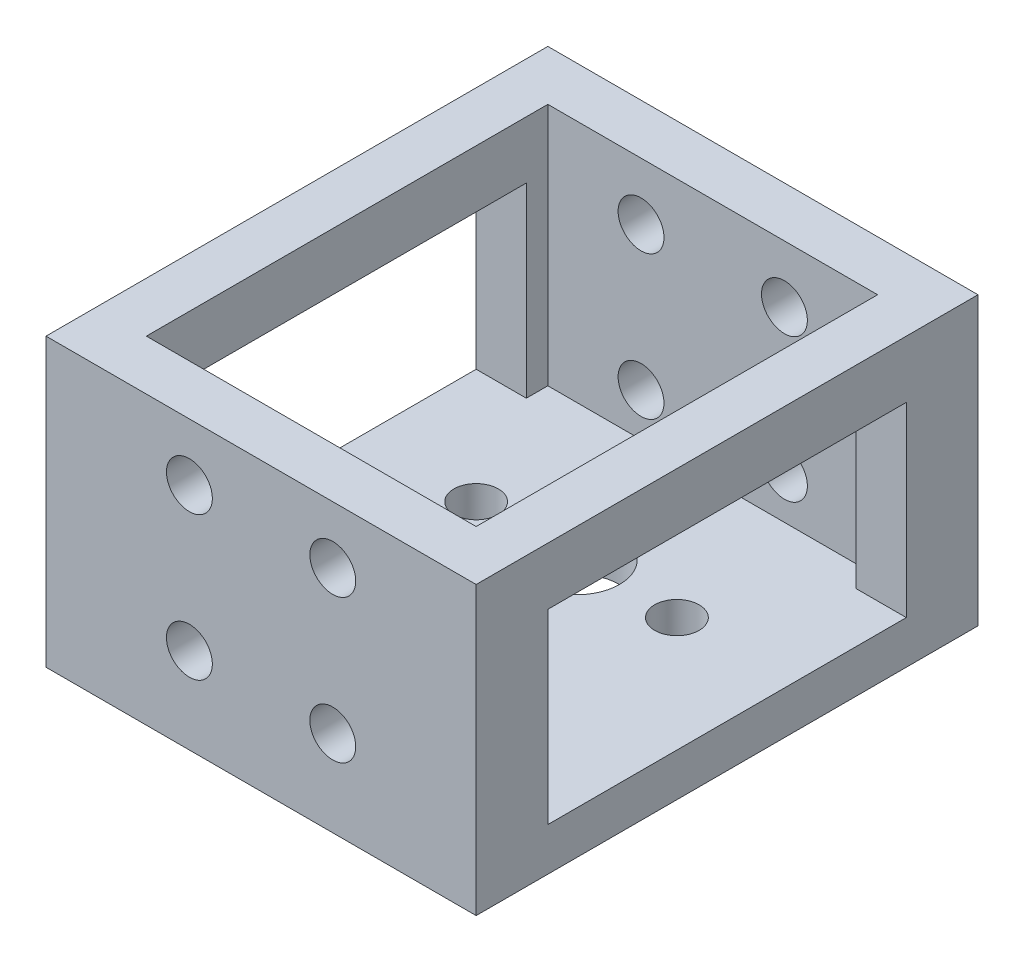
from build123d import *

# Parameters (mm, degrees)
SKETCH_1_W          = 23
SKETCH_1_H          = 35
EXTRUDE_2_DEPTH     = 3
SKETCH_1_4_W        = 23
SKETCH_1_4_H        = 3.5
EXTRUDE_3_DEPTH     = 18
EXTRUDE_3_2_DEPTH   = 18
SKETCH_1_5_W        = 30
SKETCH_1_5_H        = 35
SKETCH_1_5_W_2      = 23
SKETCH_1_5_H_2      = 28
EXTRUDE_4_DEPTH     = 20
CUT_EXTRUDE_5_DEPTH = 41.078048855
SKETCH_9_R          = 1.55
SKETCH_9_R_2        = 3
CUT_EXTRUDE_6_DEPTH = 31.516389039
SKETCH_10_R         = 1.6
CUT_EXTRUDE_7_DEPTH = 44.011626335


with BuildPart() as part:
    # 草图1 → 凸台-拉伸2 (new body)
    with BuildSketch(Plane(origin=(0, 0, 0), x_dir=(1, 0, 0), z_dir=(0, 1, 0))):
        Rectangle(SKETCH_1_W, SKETCH_1_H)
    extrude(amount=EXTRUDE_2_DEPTH)



with BuildPart() as body_2:
    # 草图1<4> → 凸台-拉伸3 (new body)
    with BuildSketch(Plane(origin=(0, 0, 0), x_dir=(1, 0, 0), z_dir=(0, 1, 0))):
        with Locations((0, 15.75)):
            Rectangle(SKETCH_1_4_W, SKETCH_1_4_H)
    extrude(amount=EXTRUDE_3_DEPTH)


with BuildPart() as body_3:
    # 草图1<4> → Extrude 3 2 (new body)
    with BuildSketch(Plane(origin=(0, 0, 0), x_dir=(1, 0, 0), z_dir=(0, 1, 0))):
        with Locations((0, -15.75)):
            Rectangle(SKETCH_1_4_W, SKETCH_1_4_H)
    extrude(amount=EXTRUDE_3_2_DEPTH)


with BuildPart() as part_1:
    add(part.part)

    add(body_2.part)  # 凸台-拉伸4 merges body 2

    add(body_3.part)  # 凸台-拉伸4 merges body 3
    # 草图1<5> → 凸台-拉伸4 (add)
    with BuildSketch(Plane(origin=(0, 0, 0), x_dir=(1, 0, 0), z_dir=(0, 1, 0))):
        Rectangle(SKETCH_1_5_W, SKETCH_1_5_H)
        Rectangle(SKETCH_1_5_W_2, SKETCH_1_5_H_2, mode=Mode.SUBTRACT)
    extrude(amount=EXTRUDE_4_DEPTH)

    # 草图8 → 切除-拉伸5 (cut, through all)
    with BuildSketch(Plane.ZY.offset(15)):
        Polygon((12.5, 3), (12.5, 10), (12.5, 16), (-12.5, 16), (-12.5, 3), (0, 3), align=None)
    extrude(amount=-CUT_EXTRUDE_5_DEPTH, mode=Mode.SUBTRACT)

    # 草图9 → 切除-拉伸6 (cut, through all)
    with BuildSketch(Plane.XZ):
        with Locations((0, -11.5)):
            Circle(SKETCH_9_R)
        with Locations((0, 2.5)):
            Circle(SKETCH_9_R)
        with Locations((7, -4.5)):
            Circle(SKETCH_9_R)
        with Locations((-7, -4.5)):
            Circle(SKETCH_9_R)
        with Locations((0, -4.5)):
            Circle(SKETCH_9_R_2)
    extrude(amount=-CUT_EXTRUDE_6_DEPTH, mode=Mode.SUBTRACT)

    # 草图10 → 切除-拉伸7 (cut, through all)
    with BuildSketch(Plane(origin=(0, 0, -17.5), x_dir=(-1, 0, 0), z_dir=(0, 0, -1))):
        with Locations((5, 6)):
            Circle(SKETCH_10_R)
        with Locations((-5, 6)):
            Circle(SKETCH_10_R)
        with Locations((-5, 16)):
            Circle(SKETCH_10_R)
        with Locations((5, 16)):
            Circle(SKETCH_10_R)
    extrude(amount=-CUT_EXTRUDE_7_DEPTH, mode=Mode.SUBTRACT)


solid = part_1.part
